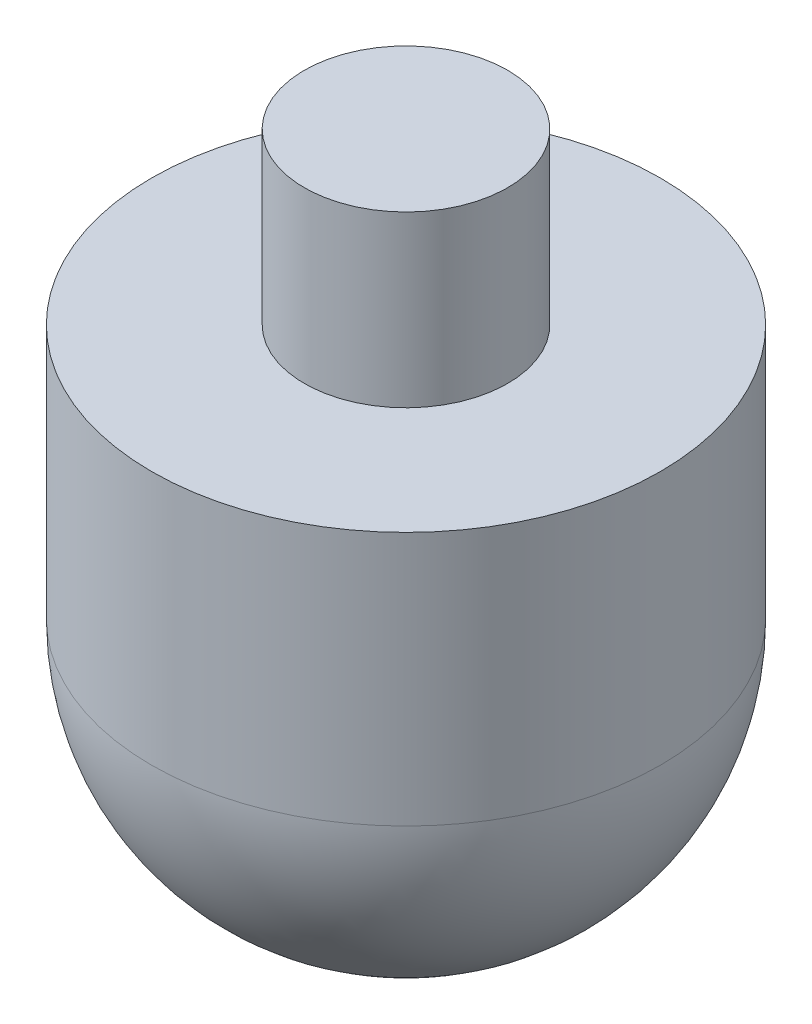
from build123d import *


with BuildPart() as part:
    # Sketch1 → Revolve1 (revolve)
    with BuildSketch(Plane.XY, mode=Mode.PRIVATE) as revolve1_sk:
        with BuildLine():
            Line((0, 0), (6, 0))
            Line((6, 0), (6, -10))
            Line((6, -10), (15, -10))
            Line((15, -10), (15, -25))
            ThreePointArc((15, -25), (10.606601718, -35.606601718), (0, -40))
            Line((0, -40), (0, 0))
        make_face()
    revolve(revolve1_sk.sketch.rotate(Axis((0, 0, 0), (0, 1, 0)), 90), axis=Axis((0, 0, 0), (0, 1, 0)))  # turned: the seam where the file's is


solid = part.part
